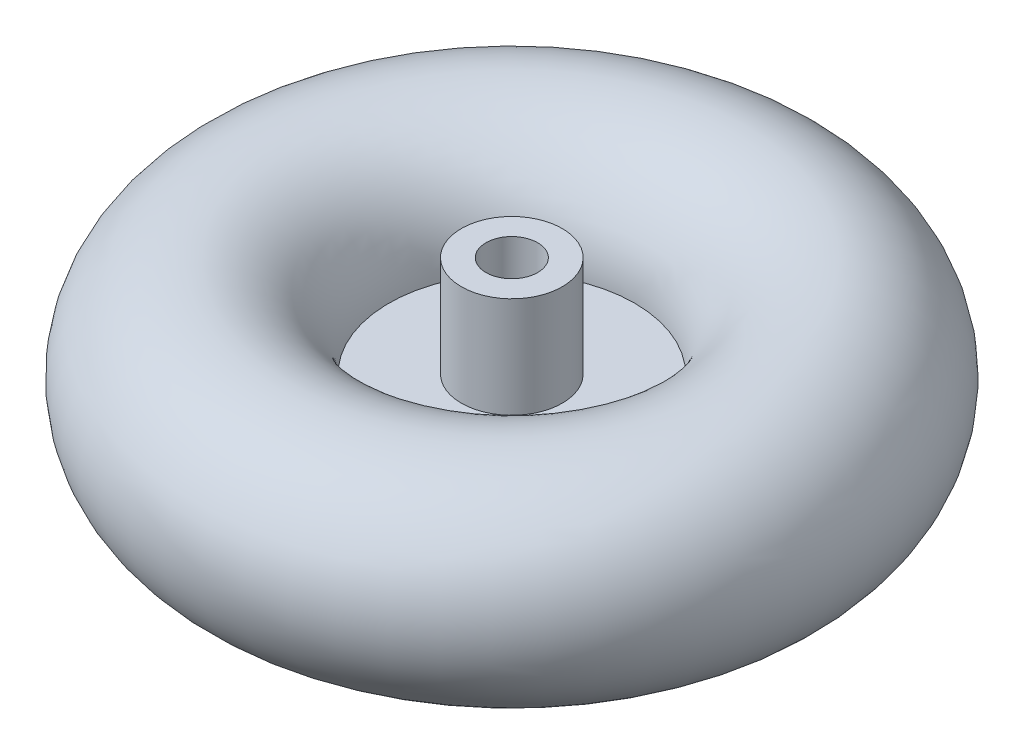
from build123d import *

# Parameters (mm, degrees)
SKETCH1_R           = 40
SKETCH3_R           = 82.354581533
BOSS_EXTRUDE1_DEPTH = 1
SKETCH4_R           = 19.5
SKETCH4_R_2         = 10
BOSS_EXTRUDE2_DEPTH = 39
SKETCH5_R           = 10
CUT_EXTRUDE1_DEPTH  = 42.0000001


with BuildPart() as part:
    # Sketch1 → Revolve1 (revolve)
    with BuildSketch(Plane.XY):
        with Locations((87.5, 0)):
            Circle(SKETCH1_R)
    revolve(axis=Axis((0, -1000, 0), (0, 1, 0)))

    # Sketch3 → Boss-Extrude1 (add, symmetric)
    with BuildSketch(Plane(origin=(0, 0, 0), x_dir=(1, 0, 0), z_dir=(0, 1, 0))):
        Circle(SKETCH3_R)
    extrude(amount=BOSS_EXTRUDE1_DEPTH, both=True)

    # Sketch4 → Boss-Extrude2 (add)
    with BuildSketch(Plane(origin=(0, 1, 0), x_dir=(1, 0, 0), z_dir=(0, 1, 0))):
        with Locations(Location((0, 0, 0), (0, 0, 270))):  # turned: the seam where the file's is
            Circle(SKETCH4_R)
        with Locations(Location((0, 0, 0), (0, 0, 270))):  # turned: the seam where the file's is
            Circle(SKETCH4_R_2, mode=Mode.SUBTRACT)
    extrude(amount=BOSS_EXTRUDE2_DEPTH)

    # Sketch5 → Cut-Extrude1 (cut, through all)
    with BuildSketch(Plane(origin=(0, 1, 0), x_dir=(1, 0, 0), z_dir=(0, 1, 0))):
        with Locations(Location((0, 0, 0), (0, 0, 270))):  # turned: the seam where the file's is
            Circle(SKETCH5_R)
    extrude(amount=-CUT_EXTRUDE1_DEPTH, mode=Mode.SUBTRACT)


solid = part.part
